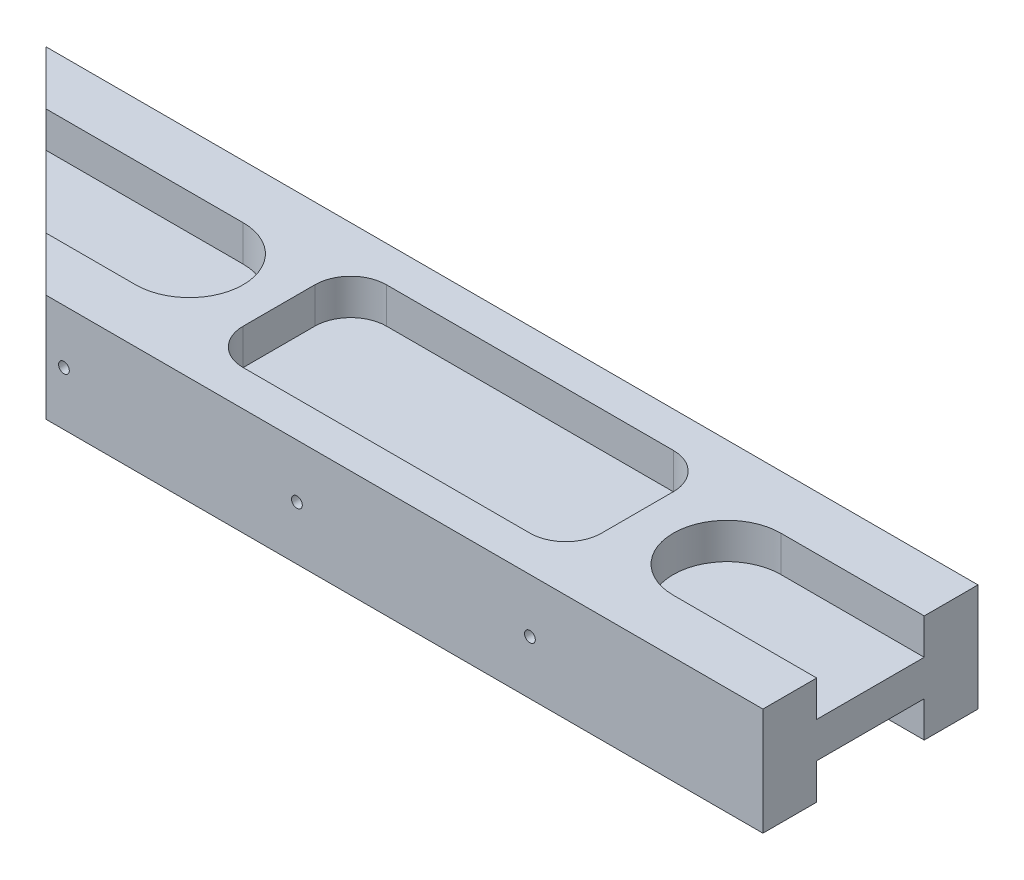
from build123d import *

# Parameters (mm, degrees)
BOSS_EXTRUDE1_DEPTH = 15
CUT_EXTRUDE1_DEPTH  = 5
CUT_EXTRUDE2_DEPTH  = 5
SKETCH4_R           = 0.75
CUT_EXTRUDE3_DEPTH  = 30
CUT_EXTRUDE4_DEPTH  = 5


with BuildPart() as part:
    # Sketch1 → Boss-Extrude1 (new body)
    with BuildSketch(Plane(origin=(0, 0, 0), x_dir=(1, 0, 0), z_dir=(0, 1, 0))):
        Polygon((0, 0), (-100, 0), (-130, 30), (0, 30), align=None)
    extrude(amount=BOSS_EXTRUDE1_DEPTH)

    # Sketch2 → Cut-Extrude1 (cut)
    with BuildSketch(Plane(origin=(0, 15, 0), x_dir=(1, 0, 0), z_dir=(0, 1, 0))):
        with BuildLine():
            Line((-135, 22.5), (-95, 22.5))
            ThreePointArc((-95, 22.5), (-87.5, 15), (-95, 7.5))
            Line((-95, 7.5), (-135, 7.5))
            ThreePointArc((-135, 7.5), (-142.5, 15), (-135, 22.5))
        make_face()
        with BuildLine():
            Line((20, 22.5), (-20, 22.5))
            ThreePointArc((-20, 22.5), (-27.5, 15), (-20, 7.5))
            Line((-20, 7.5), (20, 7.5))
            ThreePointArc((20, 7.5), (27.5, 15), (20, 22.5))
        make_face()
    extrude(amount=-CUT_EXTRUDE1_DEPTH, mode=Mode.SUBTRACT)

    # Sketch3 → Cut-Extrude2 (cut)
    with BuildSketch(Plane.XZ):
        with BuildLine():
            Line((0, -7.5), (0, -22.5))
            Line((0, -22.5), (-20, -22.5))
            ThreePointArc((-20, -22.5), (-27.5, -15), (-20, -7.5))
            Line((-20, -7.5), (0, -7.5))
        make_face()
        with BuildLine():
            Line((-122.5, -22.5), (-107.5, -7.5))
            Line((-107.5, -7.5), (-95, -7.5))
            ThreePointArc((-95, -7.5), (-87.5, -15), (-95, -22.5))
            Line((-95, -22.5), (-122.5, -22.5))
        make_face()
    extrude(amount=-CUT_EXTRUDE2_DEPTH, mode=Mode.SUBTRACT)

    # Sketch4 → Cut-Extrude3 (cut)
    with BuildSketch(Plane(origin=(0, 0, -30), x_dir=(-1, 0, 0), z_dir=(0, 0, -1))):
        with Locations((65, 7.5)):
            Circle(SKETCH4_R)
        with Locations((32.5, 7.5)):
            Circle(SKETCH4_R)
        with Locations((97.5, 7.5)):
            Circle(SKETCH4_R)
    extrude(amount=-CUT_EXTRUDE3_DEPTH, mode=Mode.SUBTRACT)

    # Sketch5 → Cut-Extrude4 (cut)
    with BuildSketch(Plane(origin=(0, 15, 0), x_dir=(1, 0, 0), z_dir=(0, 1, 0))):
        with BuildLine():
            Line((-77.5, 25), (-37.5, 25))
            ThreePointArc((-37.5, 25), (-33.964466094, 23.535533906), (-32.5, 20))
            Line((-32.5, 20), (-32.5, 10))
            ThreePointArc((-32.5, 10), (-33.964466094, 6.464466094), (-37.5, 5))
            Line((-37.5, 5), (-77.5, 5))
            ThreePointArc((-77.5, 5), (-81.035533906, 6.464466094), (-82.5, 10))
            Line((-82.5, 10), (-82.5, 20))
            ThreePointArc((-82.5, 20), (-81.035533906, 23.535533906), (-77.5, 25))
        make_face()
    extrude(amount=-CUT_EXTRUDE4_DEPTH, mode=Mode.SUBTRACT)


solid = part.part
